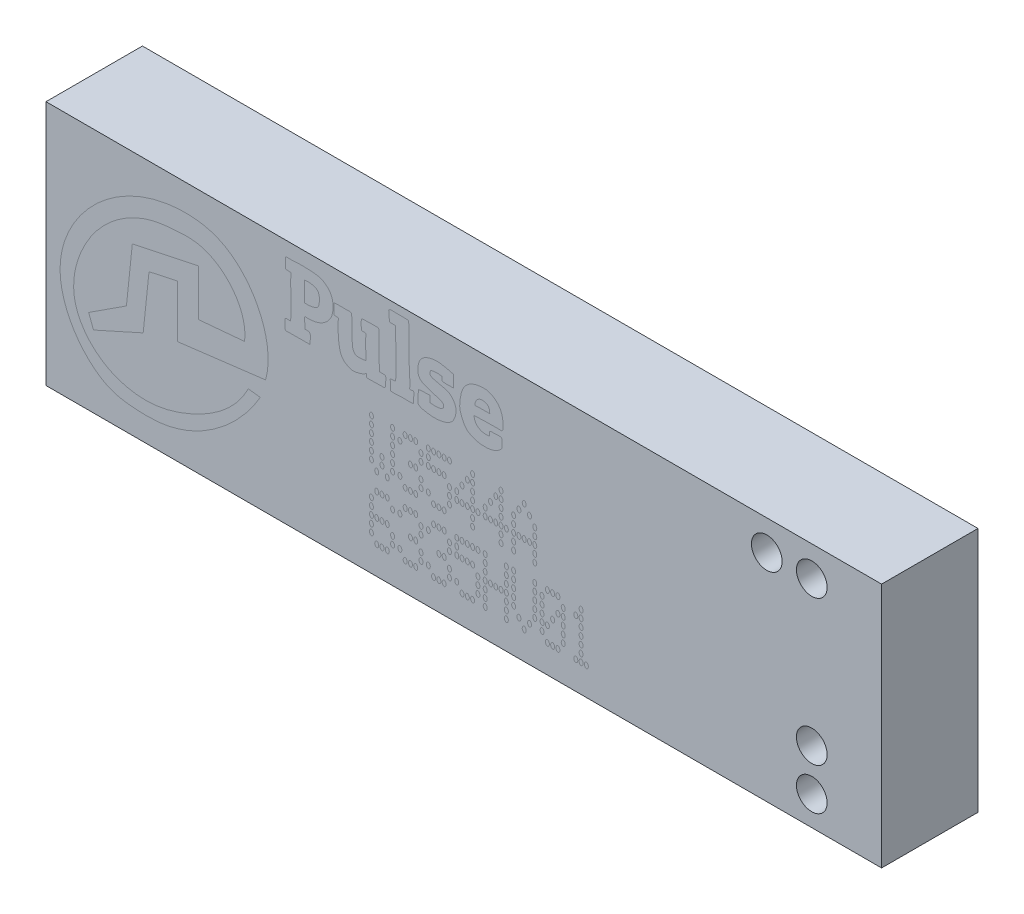
from build123d import *

# Parameters (mm, degrees)
SKETCH1_W           = 26
SKETCH1_H           = 7.65
BOSS_EXTRUDE1_DEPTH = 3
SKETCH4_R           = 0.47776384
CUT_EXTRUDE1_DEPTH  = 3


with BuildPart() as part:
    # Sketch1 → Boss-Extrude1 (new body)
    with BuildSketch(Plane.XY):
        Rectangle(SKETCH1_W, SKETCH1_H)
    extrude(amount=BOSS_EXTRUDE1_DEPTH)

    # Sketch4 → Cut-Extrude1 (cut)
    with BuildSketch(Plane.XY.offset(3)):
        with Locations((9.427906714, 2.887741852)):
            Circle(SKETCH4_R)
        with Locations((10.827906714, 2.887741852)):
            Circle(SKETCH4_R)
        with Locations((10.827906714, -1.617788566)):
            Circle(SKETCH4_R)
        with Locations((10.827906714, -2.917788566)):
            Circle(SKETCH4_R)
    extrude(amount=-CUT_EXTRUDE1_DEPTH, mode=Mode.SUBTRACT)


solid = part.part
